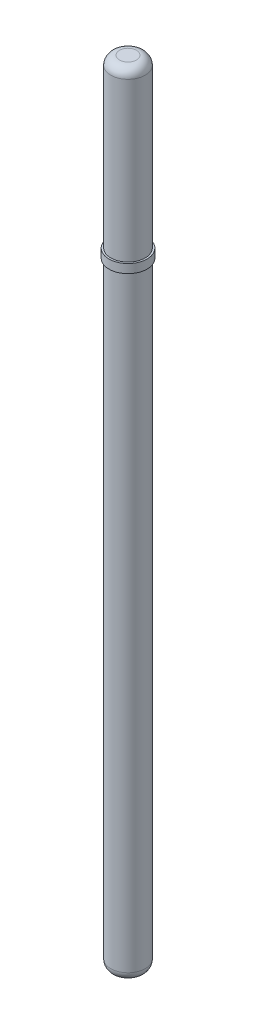
from build123d import *

# Parameters (mm, degrees)
SKETCH_1_R        = 0.98
EXTRUDE_1_DEPTH   = 45
FILLET_1_R        = 0.5
SKETCH_2_R        = 1.08
SKETCH_2_R_2      = 0.98
EXTRUDE_1_2_DEPTH = 0.5


with BuildPart() as part:
    # 草图1 → Extrude 1 (new body)
    with BuildSketch(Plane(origin=(0, 0, 0), x_dir=(1, 0, 0), z_dir=(0, 1, 0))):
        Circle(SKETCH_1_R)
    extrude(amount=EXTRUDE_1_DEPTH)

    # 圆角1
    fillet_1_edges = [part.edges().sort_by_distance(p)[0] for p in [
        (-0.98, 0, 0),
        (-0.98, 45, 0),
    ]]
    fillet(fillet_1_edges, radius=FILLET_1_R)

    # 草图2 → Extrude 1 2 (add)
    with BuildSketch(Plane(origin=(0, 35.5, 0), x_dir=(1, 0, 0), z_dir=(0, 1, 0))):
        Circle(SKETCH_2_R)
        Circle(SKETCH_2_R_2, mode=Mode.SUBTRACT)
    extrude(amount=-EXTRUDE_1_2_DEPTH)


solid = part.part
